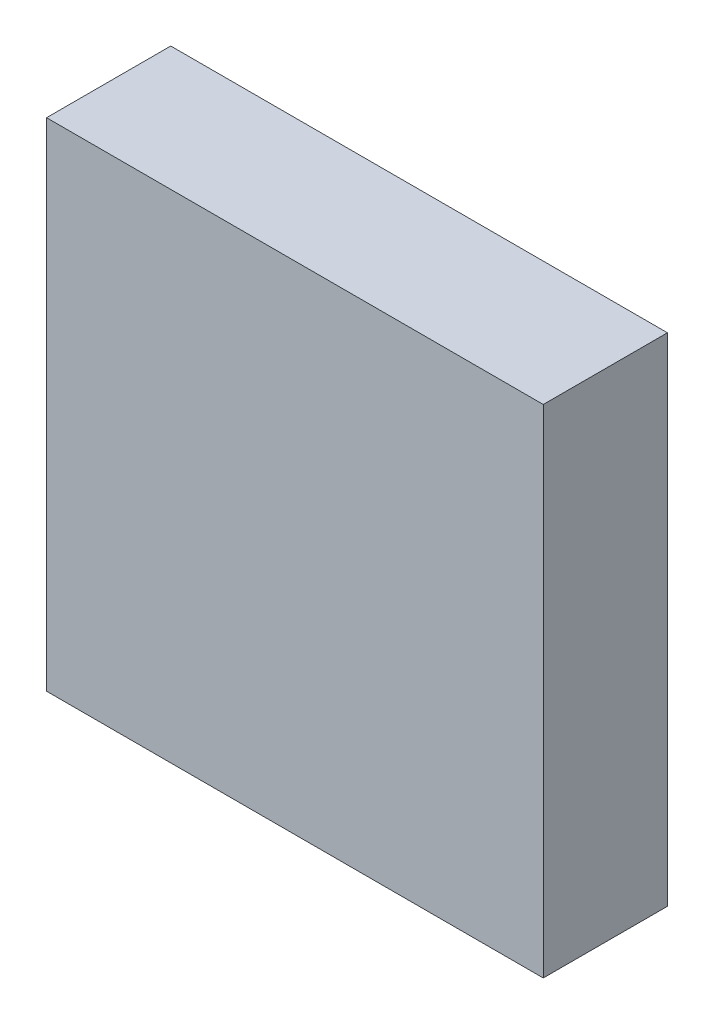
from build123d import *

# Parameters (mm, degrees)
ESQUISSE3_W        = 120
ESQUISSE3_H        = 120
BOSS_EXTRU_1_DEPTH = 30


with BuildPart() as part:
    # Esquisse3 → Boss.-Extru.1 (new body)
    with BuildSketch(Plane.XY):
        with Locations((60, 60)):
            Rectangle(ESQUISSE3_W, ESQUISSE3_H)
    extrude(amount=BOSS_EXTRU_1_DEPTH)


solid = part.part
